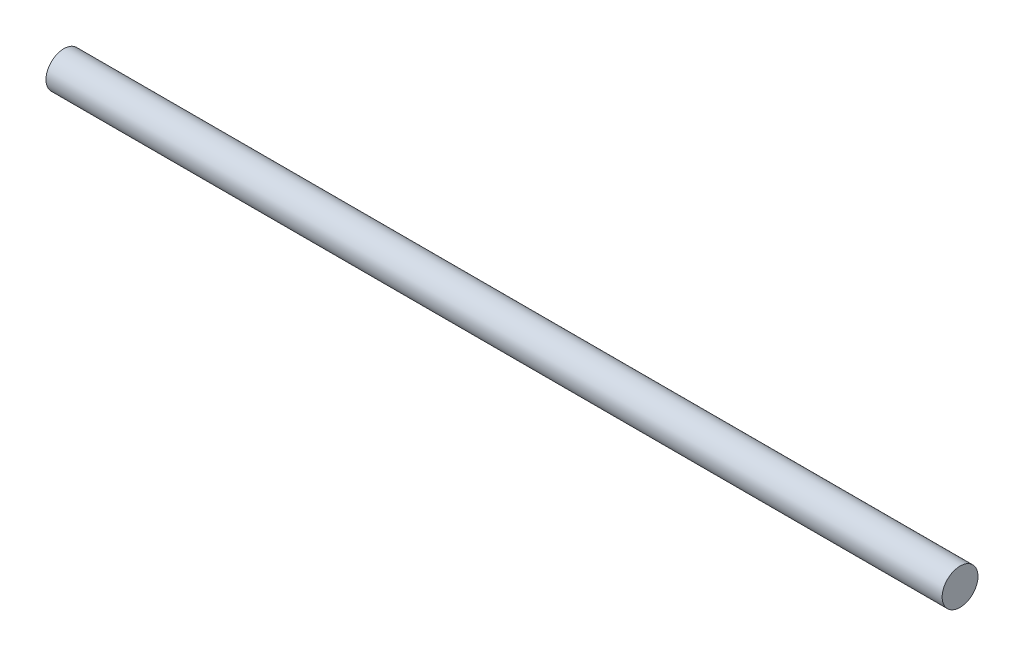
from build123d import *

# Parameters (mm, degrees)
SKETCH1_R           = 17.5
BOSS_EXTRUDE2_DEPTH = 437.5


with BuildPart() as part:
    # Sketch1 → Boss-Extrude2 (new body, symmetric)
    with BuildSketch(Plane(origin=(0, 0, 0), x_dir=(0, 0, -1), z_dir=(1, 0, 0))):
        Circle(SKETCH1_R)
    extrude(amount=BOSS_EXTRUDE2_DEPTH, both=True)


solid = part.part
